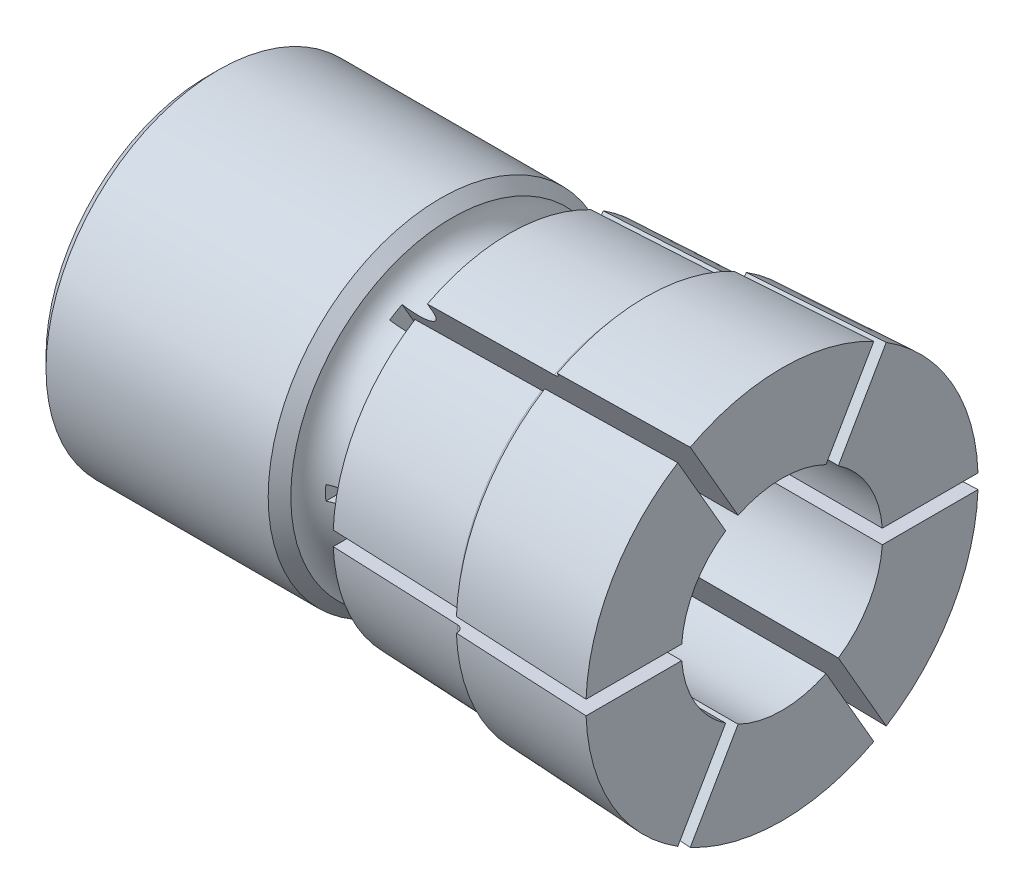
from build123d import *

# Parameters (mm, degrees)
CUT_EXTRUDE1_DEPTH = 6
CUT_EXTRUDE2_DEPTH = 40


with BuildPart() as part:
    # Sketch1 → Revolve1 (revolve)
    with BuildSketch(Plane.XY):
        with BuildLine():
            Line((8.054036255, 0), (0, 4.65))
            Line((0, 4.65), (0, 11.233))
            Line((0, 11.233), (0.767, 12))
            Line((0.767, 12), (16.233, 12))
            Line((16.233, 12), (17.020818174, 11.212181826))
            ThreePointArc((17.020818174, 11.212181826), (19.144285046, 9.505211333), (21, 11.5))
            Line((21, 11.5), (21, 12.25))
            Line((21, 12.25), (30.021033995, 12.62983301))
            ThreePointArc((30.021033995, 12.62983301), (30.360913423, 12.783353536), (30.5, 13.129390385))
            Line((30.5, 13.129390385), (30.5, 13.175))
            Line((30.5, 13.175), (40, 13.65))
            Line((40, 13.65), (40, 0))
            Line((40, 0), (8.054036255, 0))
        make_face()
    revolve(axis=Axis((40, 0, 0), (-1, 0, 0)))

    # Sketch2 → Cut-Extrude1 (cut)
    with BuildSketch(Plane(origin=(0, 0, 0), x_dir=(0, 0, -1), z_dir=(1, 0, 0))):
        Polygon((-4, -2.309401077), (0, -4.618802154), (4, -2.309401077), (4, 2.309401077), (0, 4.618802154), (-4, 2.309401077), align=None)
    extrude(amount=CUT_EXTRUDE1_DEPTH, mode=Mode.SUBTRACT)

    # Sketch3 → Cut-Revolve1 (revolve, cut)
    with BuildSketch(Plane(origin=(0, 0, 0), x_dir=(1, 0, 0), z_dir=(0, 1, 0))):
        Polygon((6, 0), (6, 4.75), (8, 4.75), (8, 3.5), (10, 3.5), (10, 7.2), (12, 7.2), (12, 7), (42, 7), (42, 0), align=None)
    revolve(axis=Axis((42, 0, 0), (-1, 0, 0)), mode=Mode.SUBTRACT)

    # Sketch4 → Cut-Extrude2 (cut)
    with BuildSketch(Plane(origin=(18, 0, 0), x_dir=(0, 0, -1), z_dir=(1, 0, 0))):
        Polygon((-18.65, 0.5), (-18.65, -0.5), (-0.866025404, -0.5), (-9.758012702, -15.901373781), (-8.891987298, -16.401373781), (0, -1), (8.891987298, -16.401373781), (9.758012702, -15.901373781), (0.866025404, -0.5), (18.65, -0.5), (18.65, 0.5), (0.866025404, 0.5), (9.758012702, 15.901373781), (8.891987298, 16.401373781), (0, 1), (-8.891987298, 16.401373781), (-9.758012702, 15.901373781), (-0.866025404, 0.5), align=None)
    extrude(amount=CUT_EXTRUDE2_DEPTH, mode=Mode.SUBTRACT)


solid = part.part
